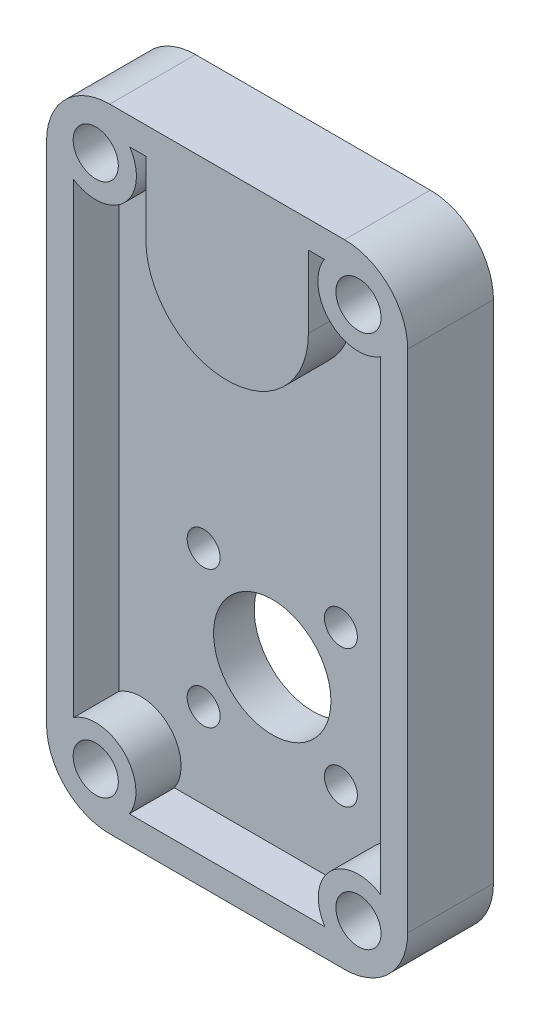
from build123d import *

# Parameters (mm, degrees)
SKETCH1_W           = 40
SKETCH1_H           = 70
SKETCH1_R           = 1.825
SKETCH1_R_2         = 6.5
BOSS_EXTRUDE1_DEPTH = 4.5
SKETCH3_W           = 40
SKETCH3_H           = 70
BOSS_EXTRUDE2_DEPTH = 5
SKETCH6_R           = 2.5
CUT_EXTRUDE3_DEPTH  = 7
SKETCH4_R           = 7
CUT_EXTRUDE1_DEPTH  = 7.5
TEXT_4108_DEPTH     = 1
FILLET1_R           = 7


with BuildPart() as part:
    # Sketch1 → Boss-Extrude1 (new body)
    with BuildSketch(Plane.XY):
        with Locations((20, 35)):
            Rectangle(SKETCH1_W, SKETCH1_H)
        with Locations((27.601397898, 12.398602102)):
            Circle(SKETCH1_R, mode=Mode.SUBTRACT)
        with Locations((27.601397898, 27.601397898)):
            Circle(SKETCH1_R, mode=Mode.SUBTRACT)
        with Locations((12.398602102, 27.601397898)):
            Circle(SKETCH1_R, mode=Mode.SUBTRACT)
        with Locations((12.398602102, 12.398602102)):
            Circle(SKETCH1_R, mode=Mode.SUBTRACT)
        with Locations((20, 20)):
            Circle(SKETCH1_R_2, mode=Mode.SUBTRACT)
    extrude(amount=BOSS_EXTRUDE1_DEPTH)

    # Sketch3 → Boss-Extrude2 (add)
    with BuildSketch(Plane.XY.offset(4.5)):
        with Locations((20, 35)):
            Rectangle(SKETCH3_W, SKETCH3_H)
        with BuildLine():
            Line((9.164835124, 3), (30.835164876, 3))
            ThreePointArc((30.835164876, 3), (31.403374824, 8.596625176), (37, 9.164835124))
            Line((37, 9.164835124), (37, 60.77541393))
            ThreePointArc((37, 60.77541393), (31.368019485, 61.368019485), (30.77541393, 67))
            Line((30.77541393, 67), (29, 67))
            Line((29, 67), (29, 59))
            ThreePointArc((29, 59), (20, 50), (11, 59))
            Line((11, 59), (11, 67))
            Line((11, 67), (9.22458607, 67))
            ThreePointArc((9.22458607, 67), (8.631980515, 61.368019485), (3, 60.77541393))
            Line((3, 60.77541393), (3, 9.164835124))
            ThreePointArc((3, 9.164835124), (8.596625176, 8.596625176), (9.164835124, 3))
        make_face(mode=Mode.SUBTRACT)
    extrude(amount=BOSS_EXTRUDE2_DEPTH)

    # Sketch6 → Cut-Extrude3 (cut)
    with BuildSketch(Plane.XY.offset(9.5)):
        with Locations((5.45, 64.55)):
            Circle(SKETCH6_R)
        with Locations((5.45, 5.45)):
            Circle(SKETCH6_R)
        with Locations((34.55, 5.45)):
            Circle(SKETCH6_R)
        with Locations((34.55, 64.55)):
            Circle(SKETCH6_R)
    extrude(amount=-CUT_EXTRUDE3_DEPTH, mode=Mode.SUBTRACT)

    # Sketch4 → Cut-Extrude1 (cut)
    with BuildSketch(Plane(origin=(0, 0, 0), x_dir=(-1, 0, 0), z_dir=(0, 0, -1))):
        with Locations((-20, 59)):
            Circle(SKETCH4_R)
    extrude(amount=-CUT_EXTRUDE1_DEPTH, mode=Mode.SUBTRACT)

    # Sketch5 → Text-4108 (cut)
    with BuildSketch(Plane(origin=(0, 0, 0), x_dir=(-1, 0, 0), z_dir=(0, 0, -1))):
        Polygon((-13.709512741, 42.712001573), (-14.838819632, 43.048790435), (-13.700748718, 46.864896205), (-14.227842068, 47.022648608), (-13.917345273, 48.066819282), (-13.390251923, 47.909066878), (-13.027170994, 49.126013993), (-11.922904167, 48.79673715), (-12.285985096, 47.579790035), (-9.698094471, 46.80855606), (-10.008591266, 45.764385387), align=None)
        Polygon((-12.596481891, 46.535619362), (-13.188679407, 44.548690275), (-11.241814423, 46.13247433), align=None, mode=Mode.SUBTRACT)
        Polygon((-16.906278027, 43.478983283), (-18.677862563, 43.640491696), (-18.111957114, 49.85668761), (-16.936326104, 49.750267337), (-17.400819293, 44.64585027), (-16.121272018, 44.529413972), align=None)
        with BuildLine():
            add(Edge.make_bspline(
                [(-22.61523776, 43.40062768), (-22.6706915, 43.395259375), (-22.779754619, 43.384701312), (-22.941726661, 43.382435126), (-23.098537698, 43.391374144), (-23.250965056, 43.409750152), (-23.399105937, 43.440063724), (-23.542981215, 43.480779676), (-23.681380152, 43.534583282), (-23.815973912, 43.596114886), (-23.943948306, 43.672324641), (-24.066983117, 43.758984044), (-24.185279604, 43.856686397), (-24.296569432, 43.967374839), (-24.401888326, 44.089580118), (-24.502503404, 44.222834664), (-24.59728027, 44.36805328), (-24.687096878, 44.525731249), (-24.769885072, 44.698484287), (-24.84640886, 44.887774425), (-24.914156311, 45.095319486), (-24.978744321, 45.319236711), (-25.033939227, 45.561990664), (-25.085628689, 45.821487145), (-25.12916502, 46.098907115), (-25.152378269, 46.289757534), (-25.164316286, 46.387907328)],
                knots=[0, 0, 0, 0, 0.000167085, 0.000328613, 0.000485358, 0.00063801, 0.000788772, 0.000938563, 0.00108598, 0.001233849, 0.001382009, 0.001532067, 0.001684996, 0.001841697, 0.002002349, 0.002168616, 0.002342243, 0.002522227, 0.002712618, 0.002916514, 0.003134269, 0.003367296, 0.003615414, 0.003880841, 0.004160983, 0.004457591, 0.004457591, 0.004457591, 0.004457591], degree=3))
            add(Edge.make_bspline(
                [(-25.164316286, 46.387907328), (-25.175121035, 46.487582917), (-25.196069185, 46.68083304), (-25.213640153, 46.96364), (-25.22567863, 47.229990489), (-25.221894537, 47.480609686), (-25.212035569, 47.715492537), (-25.189468509, 47.934080416), (-25.157247472, 48.136910395), (-25.114691554, 48.324221757), (-25.062612611, 48.49824095), (-25.004401203, 48.661175195), (-24.937423486, 48.812995376), (-24.865424466, 48.954988797), (-24.785228459, 49.085789133), (-24.696967372, 49.204947661), (-24.602998358, 49.31480671), (-24.501072758, 49.413950619), (-24.391548211, 49.504162842), (-24.271961879, 49.582286015), (-24.144964771, 49.653066427), (-24.009170936, 49.714260149), (-23.865332923, 49.766984828), (-23.71241044, 49.809302473), (-23.551498647, 49.843579326), (-23.440437545, 49.857594243), (-23.383967728, 49.864720228)],
                knots=[0, 0, 0, 0, 0.000300734, 0.00058306, 0.000849924, 0.001100338, 0.001334733, 0.00155499, 0.001759174, 0.001950517, 0.002130758, 0.002303829, 0.002469217, 0.002628241, 0.002781129, 0.00292887, 0.003072682, 0.003214341, 0.003354934, 0.003497651, 0.00364224, 0.003790722, 0.003944005, 0.004101364, 0.004266372, 0.004437058, 0.004437058, 0.004437058, 0.004437058], degree=3))
            add(Edge.make_bspline(
                [(-23.383967728, 49.864720228), (-23.327265062, 49.8705122), (-23.215726293, 49.881905482), (-23.050445827, 49.885283879), (-22.890597958, 49.878158437), (-22.736696699, 49.859085674), (-22.58832877, 49.830807315), (-22.445957416, 49.790429291), (-22.309585593, 49.739003993), (-22.178351675, 49.677378661), (-22.052930504, 49.604753637), (-21.933356978, 49.520204231), (-21.819263518, 49.424129975), (-21.708692529, 49.318670742), (-21.60660476, 49.199234402), (-21.506600054, 49.071501176), (-21.413161271, 48.931156615), (-21.324811341, 48.778186764), (-21.241624435, 48.610849634), (-21.165503619, 48.425842486), (-21.095452873, 48.223161318), (-21.03381535, 48.001614508), (-20.975464224, 47.762632869), (-20.92685633, 47.504079616), (-20.880732759, 47.227956444), (-20.857897048, 47.036973092), (-20.846157231, 46.938788738)],
                knots=[0, 0, 0, 0, 0.000170934, 0.000336241, 0.000495423, 0.00065056, 0.000801077, 0.000948117, 0.00109392, 0.001237857, 0.001382592, 0.001528137, 0.001676577, 0.001829757, 0.001985931, 0.002147459, 0.00231622, 0.002491236, 0.002677128, 0.002876389, 0.00309099, 0.003320062, 0.003566032, 0.003828762, 0.004109102, 0.00440571, 0.00440571, 0.00440571, 0.00440571], degree=3))
            add(Edge.make_bspline(
                [(-20.846157231, 46.938788738), (-20.831918537, 46.802010612), (-20.804482403, 46.538456745), (-20.785751611, 46.155263739), (-20.78587905, 45.799533287), (-20.807052418, 45.470469451), (-20.84545758, 45.168372711), (-20.905701884, 44.893582422), (-20.983523013, 44.644960767), (-21.055617187, 44.494595176), (-21.090297856, 44.422262296)],
                knots=[0, 0, 0, 0, 0.000412487, 0.00079481, 0.001150381, 0.001479095, 0.001783476, 0.002062951, 0.002322285, 0.002562676, 0.002562676, 0.002562676, 0.002562676], degree=3))
            add(Edge.make_bspline(
                [(-21.090297856, 44.422262296), (-21.131991495, 44.35018505), (-21.213778079, 44.208797736), (-21.363587582, 44.019406656), (-21.527402028, 43.851753175), (-21.712128639, 43.711778236), (-21.912543269, 43.594293985), (-22.13168739, 43.504746017), (-22.366707419, 43.436655971), (-22.530953908, 43.412845919), (-22.61523776, 43.40062768)],
                knots=[0, 0, 0, 0, 0.00024951, 0.000489441, 0.000722277, 0.000950904, 0.001182605, 0.001417212, 0.001659354, 0.001914581, 0.001914581, 0.001914581, 0.001914581], degree=3))
        make_face()
        with BuildLine():
            add(Edge.make_bspline(
                [(-22.770486157, 44.511154523), (-22.722466194, 44.519005518), (-22.627902885, 44.53446609), (-22.494183817, 44.58800321), (-22.371462721, 44.662294846), (-22.279702544, 44.743336944), (-22.214125445, 44.820604013), (-22.167690593, 44.88706371), (-22.126043768, 44.961653463), (-22.090074637, 45.044976696), (-22.057888787, 45.13627751), (-22.02872596, 45.235586863), (-22.005304117, 45.343152955), (-21.986790975, 45.459824795), (-21.971141385, 45.586689081), (-21.963206192, 45.72633198), (-21.959606589, 45.878733388), (-21.960671166, 46.044105866), (-21.9688682, 46.222339095), (-21.981368529, 46.413516241), (-21.998975032, 46.618047105), (-22.014016061, 46.758526356), (-22.021788241, 46.831116462)],
                knots=[0, 0, 0, 0, 0.000145604, 0.000286731, 0.000428876, 0.000574335, 0.000651605, 0.000732531, 0.000817169, 0.000907426, 0.001004446, 0.001107461, 0.00121773, 0.001334435, 0.001461777, 0.001601025, 0.001753816, 0.001919085, 0.002097028, 0.002288993, 0.002493821, 0.002712832, 0.002712832, 0.002712832, 0.002712832], degree=3))
            add(Edge.make_bspline(
                [(-22.021788241, 46.831116462), (-22.033207787, 46.924692001), (-22.055133343, 47.104357246), (-22.097533173, 47.361282816), (-22.146412047, 47.594252691), (-22.199119323, 47.804620753), (-22.260326484, 47.990578138), (-22.326003635, 48.15421106), (-22.399456568, 48.293557599), (-22.47924156, 48.410923948), (-22.564232422, 48.508339154), (-22.652446545, 48.590474336), (-22.743868936, 48.659131578), (-22.839870187, 48.711688909), (-22.938728825, 48.751954824), (-23.041841684, 48.775366033), (-23.148539346, 48.784598456), (-23.219966296, 48.779380869), (-23.256263401, 48.776729443)],
                knots=[0, 0, 0, 0, 0.000282789, 0.000542956, 0.000780893, 0.000996797, 0.001193174, 0.001367782, 0.001525167, 0.001664769, 0.001792559, 0.001912157, 0.002025841, 0.002134557, 0.002239643, 0.002345027, 0.00245056, 0.002559599, 0.002559599, 0.002559599, 0.002559599], degree=3))
            add(Edge.make_bspline(
                [(-23.256263401, 48.776729443), (-23.290718855, 48.771469317), (-23.358636166, 48.761100751), (-23.455414591, 48.728404874), (-23.546895917, 48.68702696), (-23.628964299, 48.628281229), (-23.705983526, 48.560165587), (-23.773569987, 48.47683982), (-23.835579817, 48.382570953), (-23.86966637, 48.313076149), (-23.887273016, 48.277180164)],
                knots=[0, 0, 0, 0, 0.000104368, 0.000205726, 0.000305416, 0.000404395, 0.000507227, 0.000613027, 0.000725191, 0.000845025, 0.000845025, 0.000845025, 0.000845025], degree=3))
            add(Edge.make_bspline(
                [(-23.887273016, 48.277180164), (-23.906740704, 48.228719461), (-23.947777887, 48.126566047), (-23.98918606, 47.958065194), (-24.022818797, 47.770424323), (-24.039207043, 47.561738745), (-24.049155473, 47.333243843), (-24.042309993, 47.084218748), (-24.026468082, 46.815259778), (-24.007359288, 46.629484433), (-23.997449298, 46.533139699)],
                knots=[0, 0, 0, 0, 0.0001565, 0.000329897, 0.000519264, 0.000727944, 0.000957228, 0.001205175, 0.001474847, 0.001765369, 0.001765369, 0.001765369, 0.001765369], degree=3))
            add(Edge.make_bspline(
                [(-23.997449298, 46.533139699), (-23.98546854, 46.436246984), (-23.962440927, 46.250014381), (-23.920658994, 45.982873885), (-23.870855432, 45.740645755), (-23.815363488, 45.522695127), (-23.757413025, 45.328445971), (-23.689001734, 45.159822173), (-23.617414817, 45.014290328), (-23.537870921, 44.892250593), (-23.452383595, 44.791571639), (-23.366490839, 44.70486732), (-23.2749678, 44.635454677), (-23.181107773, 44.57974498), (-23.083429123, 44.538780006), (-22.982149591, 44.513683975), (-22.877005748, 44.502974242), (-22.806368956, 44.508398867), (-22.770486157, 44.511154523)],
                knots=[0, 0, 0, 0, 0.000292883, 0.000562936, 0.000810934, 0.001034426, 0.001237579, 0.001418457, 0.001579713, 0.001723476, 0.001854123, 0.001975412, 0.002088848, 0.002197715, 0.002302112, 0.002405355, 0.002509753, 0.002617542, 0.002617542, 0.002617542, 0.002617542], degree=3))
        make_face(mode=Mode.SUBTRACT)
        with BuildLine():
            add(Edge.make_bspline(
                [(-29.361345935, 44.860509928), (-29.440089709, 44.884458139), (-29.595716158, 44.931788547), (-29.815148568, 45.03585767), (-30.017046255, 45.166108523), (-30.200836958, 45.320001624), (-30.364154726, 45.494785815), (-30.501116898, 45.69011333), (-30.615935151, 45.901031095), (-30.66997119, 46.052413832), (-30.697233355, 46.128789175)],
                knots=[0, 0, 0, 0, 0.000246657, 0.000487485, 0.000725724, 0.000965698, 0.001204893, 0.00144111, 0.001679728, 0.001922697, 0.001922697, 0.001922697, 0.001922697], degree=3))
            add(Edge.make_bspline(
                [(-30.697233355, 46.128789175), (-30.72149485, 46.213807393), (-30.76942062, 46.381751016), (-30.796232213, 46.641878114), (-30.792180919, 46.90152247), (-30.75804041, 47.116065803), (-30.715309225, 47.284539545), (-30.673612052, 47.4062888), (-30.626625015, 47.524110368), (-30.56898687, 47.635208918), (-30.507669518, 47.743673232), (-30.434832008, 47.845082569), (-30.356785048, 47.942952721), (-30.269146352, 48.034919194), (-30.174041908, 48.122606169), (-30.069559704, 48.206285842), (-29.953456986, 48.282636735), (-29.830495039, 48.358564785), (-29.69610282, 48.427315735), (-29.552804958, 48.492101557), (-29.399340252, 48.552398946), (-29.293065609, 48.588181642), (-29.238649621, 48.606503518)],
                knots=[0, 0, 0, 0, 0.000264789, 0.00052306, 0.000781021, 0.001042027, 0.001172602, 0.001302068, 0.001427849, 0.001552711, 0.001677259, 0.001801264, 0.001926795, 0.002052558, 0.002181921, 0.002314686, 0.002453585, 0.002598521, 0.002748034, 0.00290605, 0.003070191, 0.003242427, 0.003242427, 0.003242427, 0.003242427], degree=3))
            add(Edge.make_bspline(
                [(-29.238649621, 48.606503518), (-29.180353297, 48.624479024), (-29.066433296, 48.659605933), (-28.89776318, 48.703449697), (-28.735715955, 48.737663151), (-28.580654809, 48.761729273), (-28.432624829, 48.775295256), (-28.292143063, 48.7811109), (-28.158664606, 48.775891134), (-28.031485783, 48.762149205), (-27.90902128, 48.740024676), (-27.791027415, 48.706511177), (-27.675918459, 48.66672419), (-27.563342087, 48.619091357), (-27.454622501, 48.56140711), (-27.349449698, 48.49431499), (-27.246264911, 48.420829439), (-27.114749335, 48.310006179), (-26.960902977, 48.156091766), (-26.805377607, 47.94325397), (-26.675223198, 47.707427921), (-26.614215502, 47.53662445), (-26.583150823, 47.449652556)],
                knots=[0, 0, 0, 0, 0.000182998, 0.000357607, 0.000522615, 0.000679675, 0.000828052, 0.000968366, 0.001101172, 0.001228373, 0.00135189, 0.001473997, 0.00159595, 0.00171711, 0.001840323, 0.001964675, 0.002091153, 0.002220036, 0.00248032, 0.002741746, 0.003008435, 0.003285113, 0.003285113, 0.003285113, 0.003285113], degree=3))
            add(Edge.make_bspline(
                [(-26.583150823, 47.449652556), (-26.560603001, 47.372493143), (-26.516287543, 47.22084414), (-26.486660513, 46.988196585), (-26.481238984, 46.758218783), (-26.509021359, 46.530409001), (-26.562376733, 46.304160382), (-26.648429603, 46.081966971), (-26.759709036, 45.860196899), (-26.854804171, 45.72086175), (-26.903663643, 45.649271947)],
                knots=[0, 0, 0, 0, 0.000240818, 0.000473303, 0.000701199, 0.000929331, 0.001159816, 0.001396765, 0.001642573, 0.001902329, 0.001902329, 0.001902329, 0.001902329], degree=3))
            add(Edge.make_bspline(
                [(-26.903663643, 45.649271947), (-26.846764658, 45.617647769), (-26.735302628, 45.555697716), (-26.580477555, 45.448628347), (-26.441110113, 45.331914756), (-26.316047451, 45.20622397), (-26.206737243, 45.070807976), (-26.113224805, 44.925175522), (-26.034752566, 44.770100387), (-25.996428032, 44.660262416), (-25.977181271, 44.605101274)],
                knots=[0, 0, 0, 0, 0.000195204, 0.000382394, 0.000563697, 0.000739874, 0.000913506, 0.001084719, 0.001258292, 0.001433403, 0.001433403, 0.001433403, 0.001433403], degree=3))
            add(Edge.make_bspline(
                [(-25.977181271, 44.605101274), (-25.955428531, 44.528357662), (-25.912557407, 44.377108443), (-25.88591074, 44.144664658), (-25.889312369, 43.913938309), (-25.924532635, 43.686931101), (-25.989103495, 43.466991962), (-26.08551913, 43.259812724), (-26.210901953, 43.06662845), (-26.363887591, 42.888608054), (-26.544391404, 42.728967971), (-26.749580468, 42.589686835), (-26.97931966, 42.471989072), (-27.144516663, 42.413846954), (-27.229184477, 42.384047588)],
                knots=[0, 0, 0, 0, 0.000238979, 0.000470988, 0.000698883, 0.000929429, 0.001157998, 0.001384302, 0.001612462, 0.001846851, 0.002086301, 0.002333203, 0.002589093, 0.002858134, 0.002858134, 0.002858134, 0.002858134], degree=3))
            add(Edge.make_bspline(
                [(-27.229184477, 42.384047588), (-27.31424064, 42.359295665), (-27.479926396, 42.311079981), (-27.731373485, 42.277341278), (-27.975301137, 42.270377497), (-28.211468622, 42.298815174), (-28.437705476, 42.355445229), (-28.650517271, 42.444835808), (-28.849901744, 42.562093103), (-29.033212108, 42.707297174), (-29.19628999, 42.874802038), (-29.334049384, 43.061893249), (-29.449125898, 43.263283163), (-29.501549089, 43.408942313), (-29.527862361, 43.482054399)],
                knots=[0, 0, 0, 0, 0.000265416, 0.000517019, 0.000758707, 0.00099569, 0.001228293, 0.001456158, 0.001685698, 0.001920144, 0.00215566, 0.00238478, 0.002615709, 0.002848437, 0.002848437, 0.002848437, 0.002848437], degree=3))
            add(Edge.make_bspline(
                [(-29.527862361, 43.482054399), (-29.543292592, 43.53477151), (-29.573695916, 43.638643935), (-29.597359347, 43.797654079), (-29.608673513, 43.954783227), (-29.600602628, 44.11402103), (-29.573282477, 44.281172416), (-29.52304129, 44.460945178), (-29.45243142, 44.6570748), (-29.392750978, 44.790368248), (-29.361345935, 44.860509928)],
                knots=[0, 0, 0, 0, 0.000164604, 0.000324331, 0.000481152, 0.000636582, 0.000801452, 0.000988236, 0.001195751, 0.001426236, 0.001426236, 0.001426236, 0.001426236], degree=3))
        make_face()
        with BuildLine():
            add(Edge.make_bspline(
                [(-27.542185278, 43.483306402), (-27.498366094, 43.49951241), (-27.412952662, 43.531101559), (-27.301511926, 43.606582342), (-27.209567701, 43.700554562), (-27.140198357, 43.812356423), (-27.092279361, 43.935903439), (-27.070397331, 44.067970325), (-27.07686218, 44.205738999), (-27.101369558, 44.295776851), (-27.114000182, 44.342180601)],
                knots=[0, 0, 0, 0, 0.000139743, 0.00027239, 0.000399886, 0.000531537, 0.000664302, 0.000795003, 0.000930364, 0.001074317, 0.001074317, 0.001074317, 0.001074317], degree=3))
            add(Edge.make_bspline(
                [(-27.114000182, 44.342180601), (-27.131019123, 44.387287136), (-27.164228972, 44.475305611), (-27.243063244, 44.59074751), (-27.339543782, 44.688970712), (-27.456478142, 44.762387566), (-27.58283288, 44.815567453), (-27.716230207, 44.841722779), (-27.853364677, 44.837722012), (-27.942305249, 44.814712853), (-27.987898419, 44.802917781)],
                knots=[0, 0, 0, 0, 0.000144176, 0.000281338, 0.000415903, 0.000554469, 0.000692576, 0.00082517, 0.000959187, 0.001100147, 0.001100147, 0.001100147, 0.001100147], degree=3))
            add(Edge.make_bspline(
                [(-27.987898419, 44.802917781), (-28.033039931, 44.786423182), (-28.120399216, 44.754502312), (-28.234471865, 44.676323236), (-28.328915535, 44.580215378), (-28.400296761, 44.465016176), (-28.448299913, 44.337398939), (-28.468307138, 44.200133024), (-28.46090602, 44.056128418), (-28.434665881, 43.961629157), (-28.421091528, 43.912743502)],
                knots=[0, 0, 0, 0, 0.000143692, 0.000278076, 0.000410883, 0.000545321, 0.000681599, 0.000817053, 0.000958729, 0.001110567, 0.001110567, 0.001110567, 0.001110567], degree=3))
            add(Edge.make_bspline(
                [(-28.421091528, 43.912743502), (-28.404489313, 43.867676918), (-28.372440576, 43.780680873), (-28.296273421, 43.666235222), (-28.200960761, 43.573428198), (-28.088277514, 43.502695785), (-27.962498765, 43.456257505), (-27.827509112, 43.436016367), (-27.684752766, 43.443743844), (-27.591066682, 43.469741785), (-27.542185278, 43.483306402)],
                knots=[0, 0, 0, 0, 0.000143692, 0.000277381, 0.000408417, 0.000540068, 0.000673563, 0.000807779, 0.000946954, 0.001098793, 0.001098793, 0.001098793, 0.001098793], degree=3))
        make_face(mode=Mode.SUBTRACT)
        with BuildLine():
            add(Edge.make_bspline(
                [(-28.348475342, 45.847088454), (-28.283937525, 45.870602581), (-28.158430784, 45.916330523), (-27.991600208, 46.023390087), (-27.850052465, 46.154636213), (-27.739993325, 46.310286979), (-27.658939736, 46.477190002), (-27.616355309, 46.650749761), (-27.61194008, 46.826493011), (-27.641249431, 46.938404557), (-27.65611757, 46.995175393)],
                knots=[0, 0, 0, 0, 0.000205527, 0.000399688, 0.000590129, 0.000781226, 0.000968278, 0.001143492, 0.001313783, 0.001489108, 0.001489108, 0.001489108, 0.001489108], degree=3))
            add(Edge.make_bspline(
                [(-27.65611757, 46.995175393), (-27.666427416, 47.024189505), (-27.686680298, 47.081185447), (-27.726097739, 47.16216607), (-27.772010391, 47.23698071), (-27.825510299, 47.306088032), (-27.886913588, 47.36809441), (-27.954929528, 47.425184256), (-28.03039454, 47.474980923), (-28.111599613, 47.518727007), (-28.197300324, 47.555178005), (-28.287294954, 47.581498023), (-28.37958087, 47.598767236), (-28.474710271, 47.60797784), (-28.572509231, 47.606548234), (-28.672911033, 47.594585186), (-28.776192719, 47.575143012), (-28.844439582, 47.554238409), (-28.879324701, 47.543552797)],
                knots=[0, 0, 0, 0, 9.2318e-05, 0.000181351, 0.000269606, 0.000355256, 0.000442905, 0.000530912, 0.000621195, 0.000713623, 0.000807331, 0.00090003, 0.000994322, 0.00108863, 0.001186294, 0.001287086, 0.001391687, 0.001501063, 0.001501063, 0.001501063, 0.001501063], degree=3))
            add(Edge.make_bspline(
                [(-28.879324701, 47.543552797), (-28.914145476, 47.531513444), (-28.982176145, 47.507991702), (-29.079103894, 47.465329163), (-29.167984162, 47.41679649), (-29.248715861, 47.362033502), (-29.323222919, 47.303910144), (-29.388404914, 47.238426297), (-29.445408214, 47.167162804), (-29.494865585, 47.091700054), (-29.536728645, 47.012756618), (-29.568096545, 46.931168209), (-29.589348403, 46.847885622), (-29.601889305, 46.763572883), (-29.606076074, 46.677496771), (-29.599065721, 46.589884333), (-29.584554035, 46.499925493), (-29.56693807, 46.4407933), (-29.557910438, 46.410489896)],
                knots=[0, 0, 0, 0, 0.000110496, 0.00021588, 0.0003173, 0.000413834, 0.000508276, 0.000600347, 0.000690291, 0.000781618, 0.00087066, 0.000957852, 0.001043182, 0.001127995, 0.001213214, 0.001301078, 0.00139123, 0.001485995, 0.001485995, 0.001485995, 0.001485995], degree=3))
            add(Edge.make_bspline(
                [(-29.557910438, 46.410489896), (-29.547752834, 46.380575194), (-29.527862258, 46.321996355), (-29.486473812, 46.239835782), (-29.439741598, 46.163146512), (-29.383339665, 46.094179037), (-29.322622404, 46.030005609), (-29.25384702, 45.972662097), (-29.177308833, 45.923221214), (-29.067756447, 45.864795669), (-28.920019294, 45.812136347), (-28.733352151, 45.786451823), (-28.539512242, 45.793899684), (-28.413517072, 45.828979441), (-28.348475342, 45.847088454)],
                knots=[0, 0, 0, 0, 9.4665e-05, 0.000185373, 0.000275352, 0.000363536, 0.000452083, 0.000540089, 0.000631417, 0.000724949, 0.000912252, 0.001098165, 0.001287421, 0.00148937, 0.00148937, 0.00148937, 0.00148937], degree=3))
        make_face(mode=Mode.SUBTRACT)
    extrude(amount=-TEXT_4108_DEPTH, mode=Mode.SUBTRACT)

    # Fillet1
    fillet1_edges = [part.edges().sort_by_distance(p)[0] for p in [
        (0, 70, 4.75),
        (40, 70, 4.75),
        (40, 0, 4.75),
        (0, 0, 4.75),
    ]]
    fillet(fillet1_edges, radius=FILLET1_R)


solid = part.part
